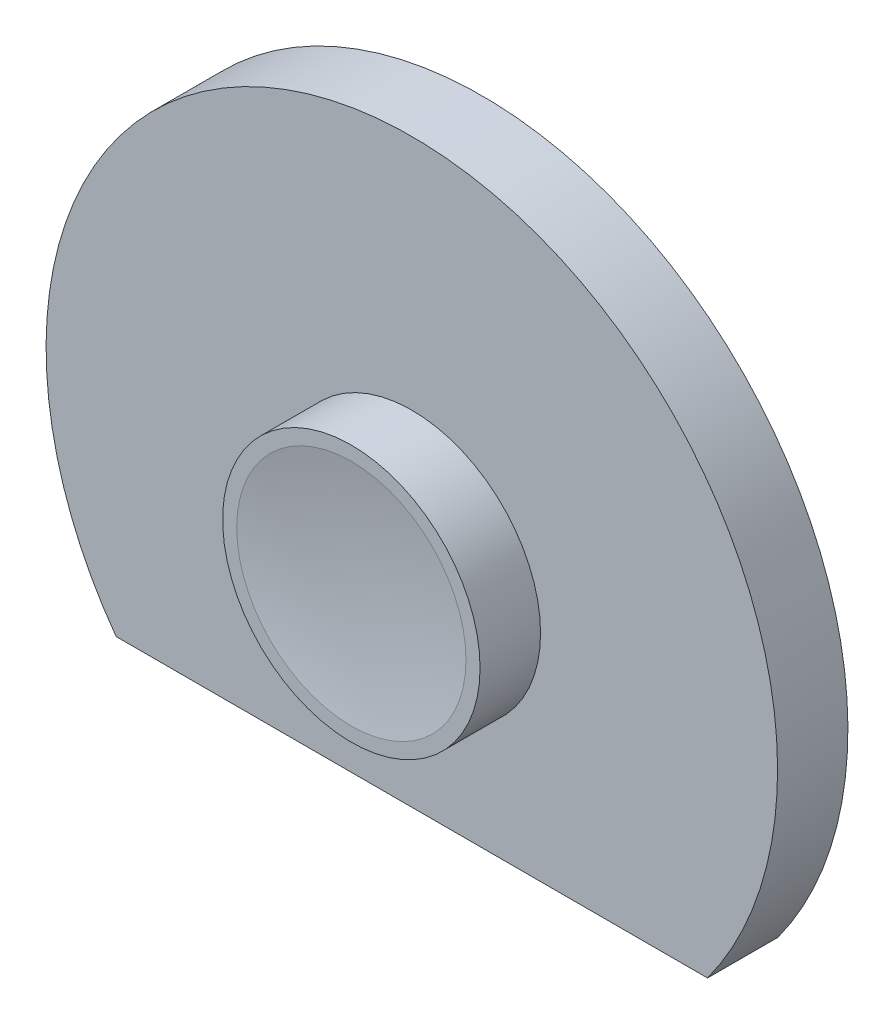
from build123d import *

# Parameters (mm, degrees)
BOSS_EXTRUDE1_DEPTH = 5
SKETCH2_R           = 9.15
BOSS_EXTRUDE2_DEPTH = 4.3


with BuildPart() as part:
    # Sketch1 → Boss-Extrude1 (new body)
    with BuildSketch(Plane.XY):
        with BuildLine():
            Line((-21.021655501, -15.3), (21.021655501, -15.3))
            ThreePointArc((21.021655501, -15.3), (0, 26), (-21.021655501, -15.3))
        make_face()
    extrude(amount=BOSS_EXTRUDE1_DEPTH)

    # Sketch2 → Boss-Extrude2 (add)
    with BuildSketch(Plane.XY.offset(5)):
        Circle(SKETCH2_R)
    extrude(amount=BOSS_EXTRUDE2_DEPTH)

    # Sketch3 → Cut-Revolve1 (revolve, cut)
    with BuildSketch(Plane.XZ):
        with BuildLine():
            Line((0, 9.3), (0, 8.631303449))
            ThreePointArc((0, 8.631303449), (4.088693406, 8.798757997), (8.15, 9.3))
            Line((8.15, 9.3), (0, 9.3))
        make_face()
    revolve(axis=Axis((0, 0, 9.3), (0, 0, -1)), mode=Mode.SUBTRACT)


solid = part.part
